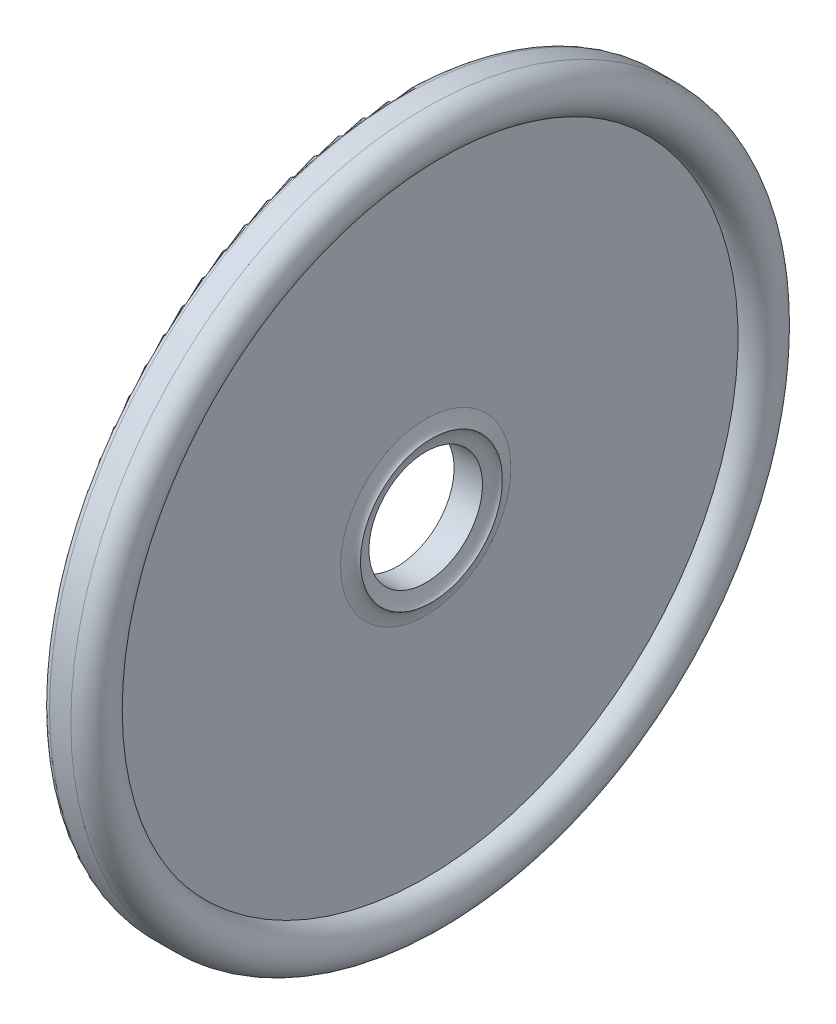
from build123d import *


with BuildPart() as part:
    # Sketch1 → Revolve1 (revolve)
    with BuildSketch(Plane(origin=(0, 0, 0), x_dir=(-1, 0, 0), z_dir=(0, 0, -1))):
        with BuildLine():
            Line((-1, 11), (-1, 3))
            add(Edge.make_bspline(
                [(-1, 3), (-1.078203591, 2.575668755), (-1.2, 2.5)],
                knots=[0, 0, 0, 0.432994338, 0.432994338, 0.432994338], degree=2))
            add(Edge.make_bspline(
                [(-1, 2), (-1.078203591, 2.424331245), (-1.2, 2.5)],
                knots=[0, 0, 0, 0.432994338, 0.432994338, 0.432994338], degree=2))
            Line((-1, 2), (0, 2))
            Line((0, 2), (0, 12.25))
            ThreePointArc((0, 12.25), (-0.073223305, 12.426776695), (-0.25, 12.5))
            Line((-0.25, 12.5), (-1, 12.5))
            ThreePointArc((-1, 12.5), (-1.75, 11.75), (-1, 11))
        make_face()
    revolve(axis=Axis((-1.443304251, 0, 0), (1, 0, 0)))


solid = part.part
